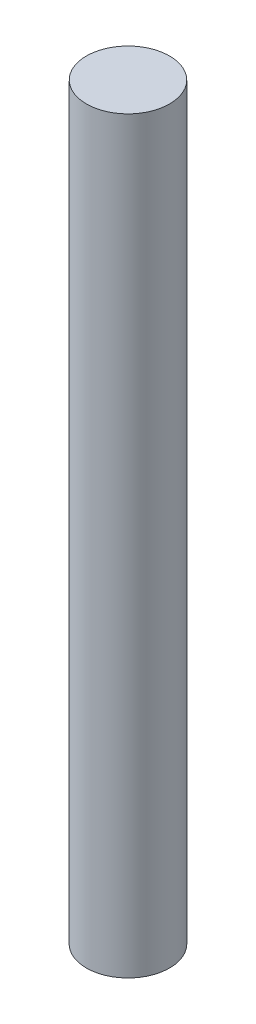
from build123d import *

# Parameters (mm, degrees)
CROQUIS1_R              = 2.5
SALIENTE_EXTRUIR1_DEPTH = 45


with BuildPart() as part:
    # Croquis1 → Saliente-Extruir1 (new body)
    with BuildSketch(Plane(origin=(0, 0, 0), x_dir=(1, 0, 0), z_dir=(0, 1, 0))):
        Circle(CROQUIS1_R)
    extrude(amount=SALIENTE_EXTRUIR1_DEPTH)


solid = part.part
